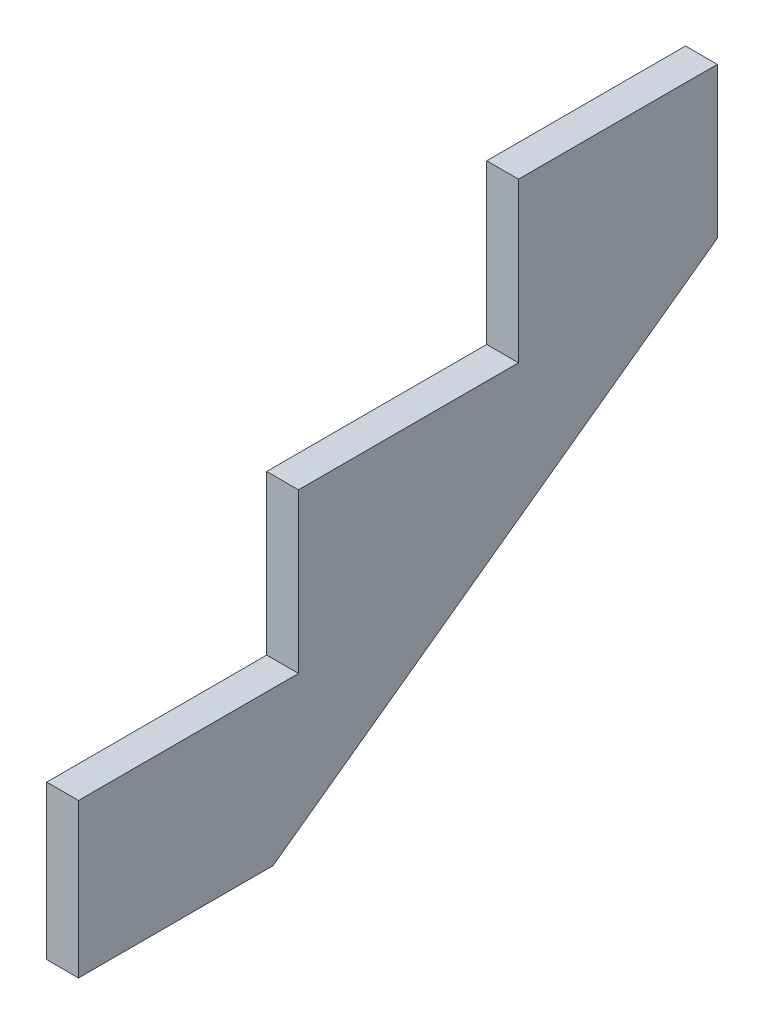
from build123d import *

# Parameters (mm, degrees)
BOSS_EXTRUDE2_DEPTH = 38.1


with BuildPart() as part:
    # Sketch1 → Boss-Extrude2 (new body)
    with BuildSketch(Plane(origin=(0, 0, 0), x_dir=(0, 0, -1), z_dir=(1, 0, 0))):
        Polygon((0, 0), (0, 184.15), (263.525, 184.15), (263.525, 374.65), (527.05, 374.65), (527.05, 565.15), (765.175, 565.15), (765.175, 384.694333673), (233.014505086, 0), align=None)
    extrude(amount=BOSS_EXTRUDE2_DEPTH)


solid = part.part
